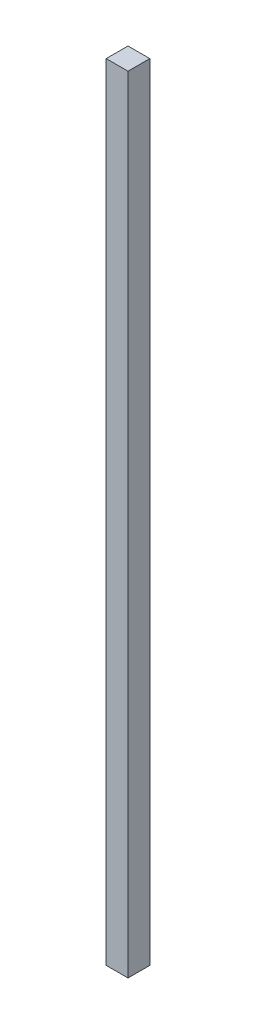
from build123d import *

# Parameters (mm, degrees)
SKETCH2_W           = 3.175
SKETCH2_H           = 114.32032
BOSS_EXTRUDE1_DEPTH = 3.175


with BuildPart() as part:
    # Sketch2 → Boss-Extrude1 (new body)
    with BuildSketch(Plane.XY):
        Rectangle(SKETCH2_W, SKETCH2_H)
    extrude(amount=BOSS_EXTRUDE1_DEPTH)


solid = part.part
